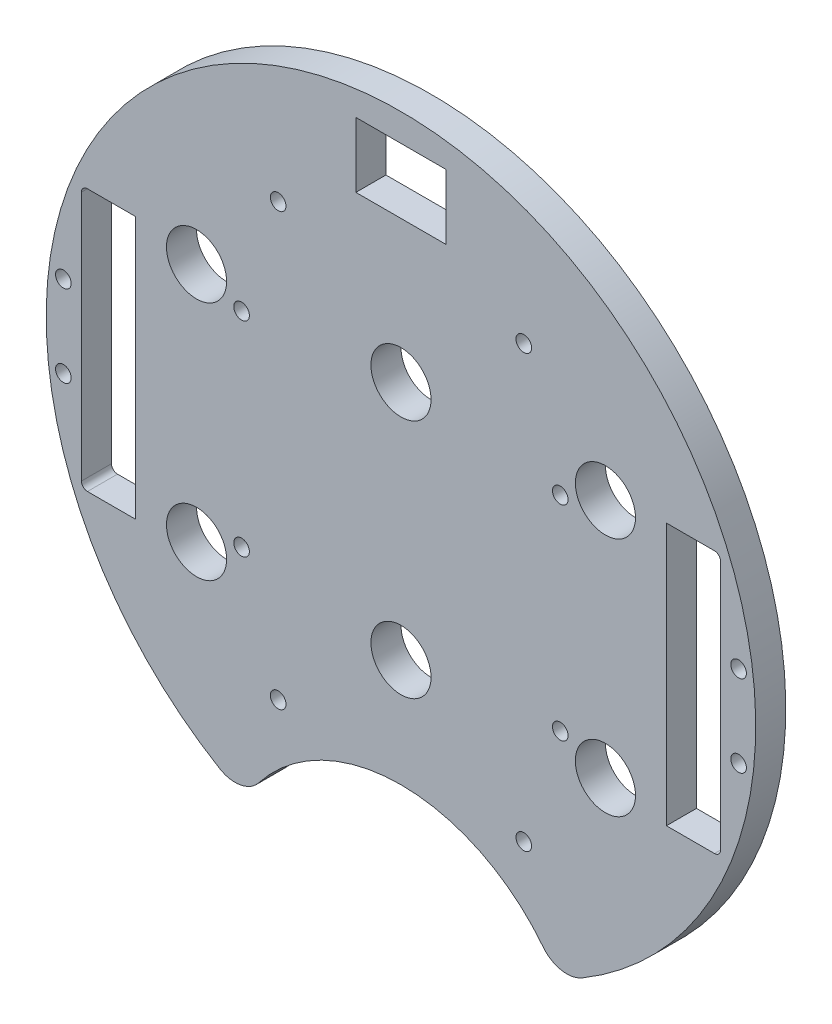
from build123d import *

# Parameters (mm, degrees)
BOSS_EXTRUDE2_DEPTH     = 6.35
SKETCH2_W               = 19.05
SKETCH2_H               = 13.716
CUT_EXTRUDE1_DEPTH      = 7.35
SKETCH3_R               = 38.1
CUT_EXTRUDE2_DEPTH      = 7.35
FILLET1_R               = 6.35
SKETCH7_R               = 3.175
CUT_EXTRUDE6_DEPTH      = 103.378
CUT_EXTRUDE6_DEPTH_BACK = 1.0000001
SKETCH8_R               = 1.651
CUT_EXTRUDE7_DEPTH      = 75.692
SKETCH10_R              = 1.651
CUT_EXTRUDE9_DEPTH      = 97.79
SKETCH11_R              = 1.651
CUT_EXTRUDE10_DEPTH     = 150.876
SKETCH12_R              = 6.35
CUT_EXTRUDE11_DEPTH     = 31.242


with BuildPart() as part:
    # Sketch1 → Boss-Extrude2 (new body)
    with BuildSketch(Plane.XY):
        with BuildLine():
            ThreePointArc((-69.525975721, 27.94), (-74.93, 0), (-69.525975721, -27.94))
            ThreePointArc((-69.525975721, -27.94), (0, -74.93), (69.525975721, -27.94))
            ThreePointArc((69.525975721, -27.94), (73.56658977, -14.228906128), (74.93, 0))
            ThreePointArc((74.93, 0), (73.56658977, 14.228906128), (69.525975721, 27.94))
            ThreePointArc((69.525975721, 27.94), (0, 74.93), (-69.525975721, 27.94))
        make_face()
        with BuildLine():
            ThreePointArc((-67.493975721, 26.416), (-67.122001333, 27.314025612), (-66.223975721, 27.686))
            Line((-66.223975721, 27.686), (-56.063975721, 27.686))
            Line((-56.063975721, 27.686), (-56.063975721, -27.686))
            Line((-56.063975721, -27.686), (-66.223975721, -27.686))
            ThreePointArc((-66.223975721, -27.686), (-67.122001333, -27.314025612), (-67.493975721, -26.416))
            Line((-67.493975721, -26.416), (-67.493975721, 26.416))
        make_face(mode=Mode.SUBTRACT)
        with BuildLine():
            ThreePointArc((66.223975721, 27.686), (67.122001333, 27.314025612), (67.493975721, 26.416))
            Line((67.493975721, 26.416), (67.493975721, -26.416))
            ThreePointArc((67.493975721, -26.416), (67.122001333, -27.314025612), (66.223975721, -27.686))
            Line((66.223975721, -27.686), (56.063975721, -27.686))
            Line((56.063975721, -27.686), (56.063975721, 27.686))
            Line((56.063975721, 27.686), (66.223975721, 27.686))
        make_face(mode=Mode.SUBTRACT)
    extrude(amount=BOSS_EXTRUDE2_DEPTH)

    # Sketch2 → Cut-Extrude1 (cut, through all)
    with BuildSketch(Plane.XY.offset(6.35)):
        with Locations((0, 62.23)):
            Rectangle(SKETCH2_W, SKETCH2_H)
    extrude(amount=-CUT_EXTRUDE1_DEPTH, mode=Mode.SUBTRACT)

    # Sketch3 → Cut-Extrude2 (cut, through all)
    with BuildSketch(Plane.XY.offset(6.35)):
        with Locations((0, -86.312058398)):
            Circle(SKETCH3_R)
    extrude(amount=-CUT_EXTRUDE2_DEPTH, mode=Mode.SUBTRACT)

    # Fillet1
    fillet1_edges = [part.edges().sort_by_distance(p)[0] for p in [
        (-33.000960548, -67.271401821, 3.175),
        (33.000960548, -67.271401821, 3.175),
    ]]
    fillet(fillet1_edges, radius=FILLET1_R)

    # Sketch7 → Cut-Extrude6 (cut, two sides)
    with BuildSketch(Plane(origin=(30.092005081, 4.08352975, 6.35), x_dir=(-1, 0, 0), z_dir=(0, 0, -1))) as cut_extrude6_sk:
        with Locations((-13.087994919, 21.31647025)):
            Circle(SKETCH7_R)
        with Locations((73.272005081, 21.31647025)):
            Circle(SKETCH7_R)
        with Locations((30.092005081, 21.31647025)):
            Circle(SKETCH7_R)
        with Locations((73.272005081, -29.48352975)):
            Circle(SKETCH7_R)
        with Locations((30.092005081, -29.48352975)):
            Circle(SKETCH7_R)
        with Locations((-13.087994919, -29.48352975)):
            Circle(SKETCH7_R)
    extrude(amount=CUT_EXTRUDE6_DEPTH, mode=Mode.SUBTRACT)
    extrude(cut_extrude6_sk.sketch, amount=-CUT_EXTRUDE6_DEPTH_BACK, mode=Mode.SUBTRACT)

    # Sketch8 → Cut-Extrude7 (cut)
    with BuildSketch(Plane(origin=(30.092005081, 4.08352975, -35.052), x_dir=(-1, 0, 0), z_dir=(0, 0, -1))):
        with Locations((63.757223581, 17.50647025)):
            Circle(SKETCH8_R)
        with Locations((63.757223581, -25.67352975)):
            Circle(SKETCH8_R)
        with Locations((-3.552776419, -25.67352975)):
            Circle(SKETCH8_R)
        with Locations((-3.552776419, 17.50647025)):
            Circle(SKETCH8_R)
    extrude(amount=-CUT_EXTRUDE7_DEPTH, mode=Mode.SUBTRACT)

    # Sketch10 → Cut-Extrude9 (cut)
    with BuildSketch(Plane(origin=(30.092005081, 4.08352975, -41.275), x_dir=(-1, 0, 0), z_dir=(0, 0, -1))):
        with Locations((4.154396091, -49.728759131)):
            Circle(SKETCH10_R)
        with Locations((56.02961407, -49.728759131)):
            Circle(SKETCH10_R)
        with Locations((4.154396091, 41.38247025)):
            Circle(SKETCH10_R)
        with Locations((56.02961407, 41.38247025)):
            Circle(SKETCH10_R)
    extrude(amount=-CUT_EXTRUDE9_DEPTH, mode=Mode.SUBTRACT)

    # Sketch11 → Cut-Extrude10 (cut)
    with BuildSketch(Plane(origin=(30.092005081, 4.08352975, 6.35), x_dir=(1, 0, 0), z_dir=(0, 0, 1))):
        with Locations((-101.395980802, -12.71952975)):
            Circle(SKETCH11_R)
        with Locations((-101.395980802, 4.55247025)):
            Circle(SKETCH11_R)
        with Locations((41.211970641, -12.71952975)):
            Circle(SKETCH11_R)
        with Locations((41.211970641, 4.55247025)):
            Circle(SKETCH11_R)
    extrude(amount=-CUT_EXTRUDE10_DEPTH, mode=Mode.SUBTRACT)

    # Sketch12 → Cut-Extrude11 (cut)
    with BuildSketch(Plane.XY.offset(6.35)):
        with Locations((0, 25.4)):
            Circle(SKETCH12_R)
        with Locations((-43.18, 25.4)):
            Circle(SKETCH12_R)
        with Locations((-43.18, -25.4)):
            Circle(SKETCH12_R)
        with Locations((0, -25.4)):
            Circle(SKETCH12_R)
        with Locations((43.18, -25.4)):
            Circle(SKETCH12_R)
        with Locations((43.18, 25.4)):
            Circle(SKETCH12_R)
    extrude(amount=-CUT_EXTRUDE11_DEPTH, mode=Mode.SUBTRACT)


solid = part.part
